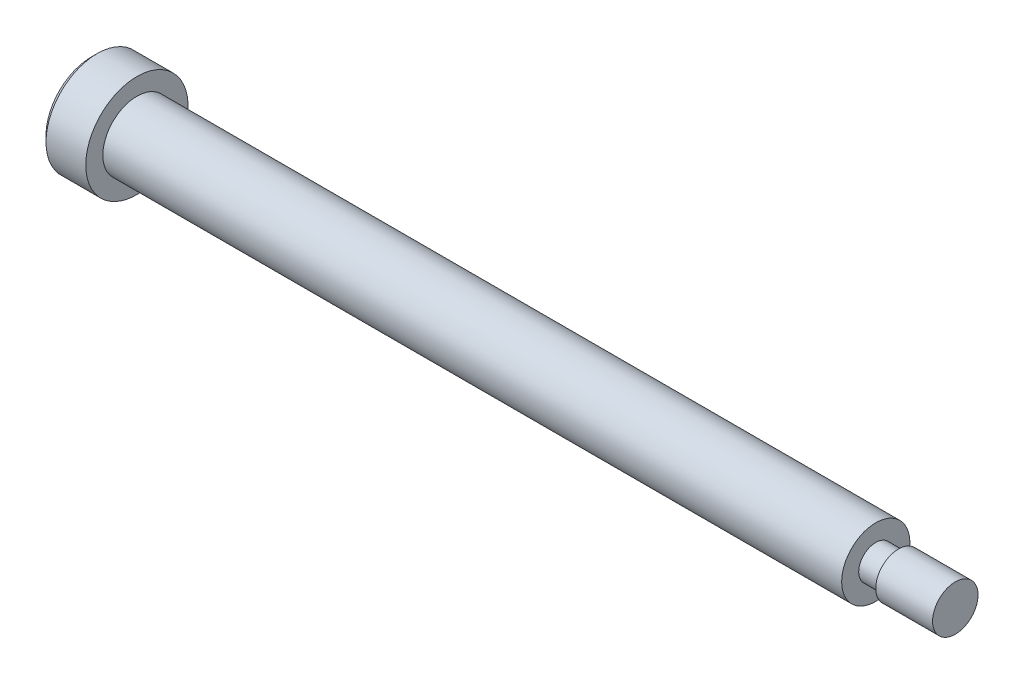
from build123d import *

# Parameters (mm, degrees)
CHAMFER2_SIZE      = 0.5
CUT_EXTRUDE1_DEPTH = 2


with BuildPart() as part:
    # Sketch1 → Revolve1 (revolve)
    with BuildSketch(Plane.XY):
        Polygon((0, 3), (65, 3), (65, 1.5), (67, 1.5), (67, 2), (72, 2), (72, 0), (-4, 0), (-4, 4.5), (0, 4.5), align=None)
    revolve(axis=Axis((-15.448246648, 0, 0), (1, 0, 0)))

    # Chamfer2
    chamfer2_edges = [part.edges().sort_by_distance(p)[0] for p in [
        (-4, -4.5, 0),
    ]]
    chamfer(chamfer2_edges, length=CHAMFER2_SIZE)

    # Sketch2 → Cut-Extrude1 (cut)
    with BuildSketch(Plane.ZY.offset(4)):
        Polygon((0, 1.732050808), (-1.5, 0.866025404), (-1.5, -0.866025404), (0, -1.732050808), (1.5, -0.866025404), (1.5, 0.866025404), align=None)
    extrude(amount=-CUT_EXTRUDE1_DEPTH, mode=Mode.SUBTRACT)


solid = part.part
